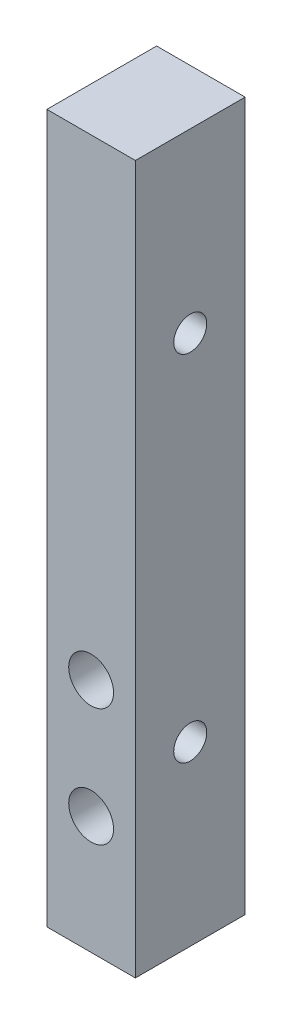
from build123d import *

# Parameters (mm, degrees)
SKETCH1_W           = 9.525
SKETCH1_H           = 76.2
BOSS_EXTRUDE1_DEPTH = 11.811
SKETCH2_R           = 1.778
CUT_EXTRUDE1_DEPTH  = 10.525
SKETCH3_R           = 2.413
CUT_EXTRUDE2_DEPTH  = 12.811


with BuildPart() as part:
    # Sketch1 → Boss-Extrude1 (new body)
    with BuildSketch(Plane.XY):
        with Locations((4.7625, 38.1)):
            Rectangle(SKETCH1_W, SKETCH1_H)
    extrude(amount=BOSS_EXTRUDE1_DEPTH)

    # Sketch2 → Cut-Extrude1 (cut, through all)
    with BuildSketch(Plane.ZY):
        with Locations((5.9055, 57.15)):
            Circle(SKETCH2_R)
        with Locations((5.9055, 19.05)):
            Circle(SKETCH2_R)
    extrude(amount=-CUT_EXTRUDE1_DEPTH, mode=Mode.SUBTRACT)

    # Sketch3 → Cut-Extrude2 (cut, through all)
    with BuildSketch(Plane(origin=(0, 0, 0), x_dir=(-1, 0, 0), z_dir=(0, 0, -1))):
        with Locations((-4.7625, 25.4)):
            Circle(SKETCH3_R)
        with Locations((-4.7625, 12.7)):
            Circle(SKETCH3_R)
    extrude(amount=-CUT_EXTRUDE2_DEPTH, mode=Mode.SUBTRACT)


solid = part.part
